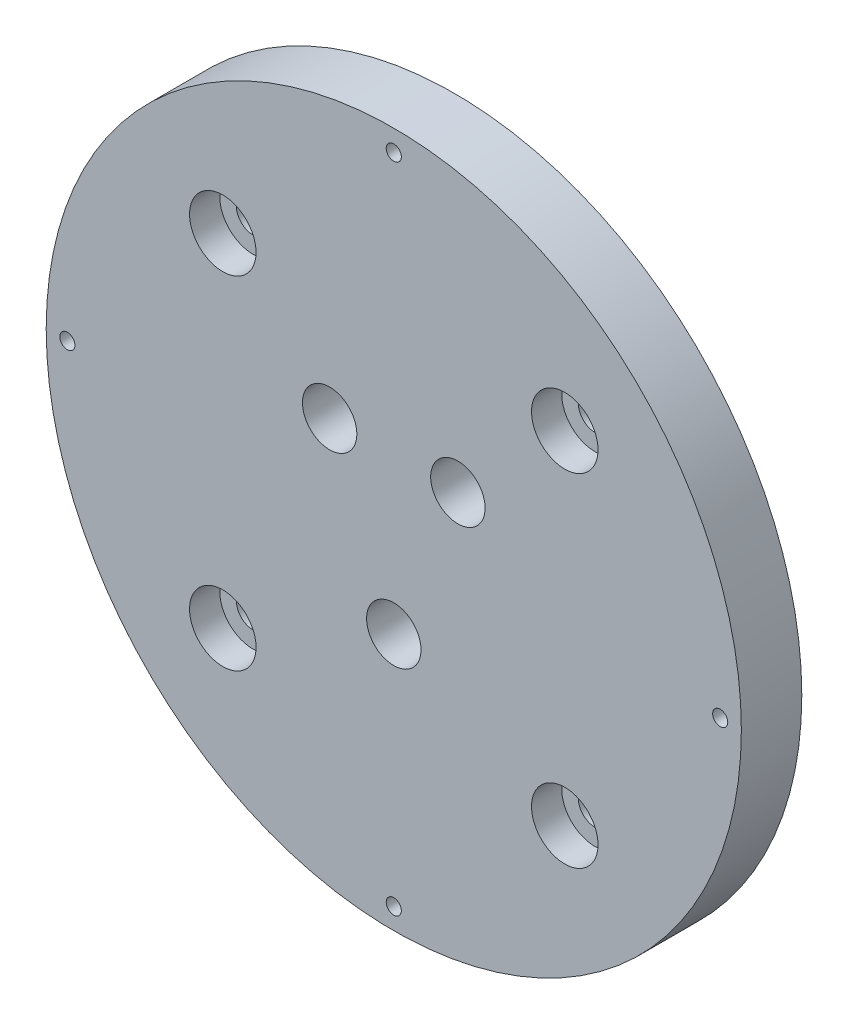
from build123d import *

# Parameters (mm, degrees)
SKETCH1_R           = 57.5
BOSS_EXTRUDE1_DEPTH = 10
SKETCH3_R           = 4.5
CUT_EXTRUDE2_DEPTH  = 10
SKETCH8_R           = 55
SKETCH8_R_2         = 53
CUT_EXTRUDE6_DEPTH  = 1.27
CIRPATTERN2_COUNT   = 4
HOLE1_D             = 5.5
HOLE1_DEPTH         = 10
HOLE1_CBORE_D       = 11
HOLE1_CBORE_DEPTH   = 5
CIRPATTERN3_COUNT   = 4


with BuildPart() as part:
    # Sketch1 → Boss-Extrude1 (new body)
    with BuildSketch(Plane.XY):
        Circle(SKETCH1_R)
    extrude(amount=BOSS_EXTRUDE1_DEPTH)

    # Sketch3 → Cut-Extrude2 (cut)
    with BuildSketch(Plane.XY.offset(10)):
        with Locations((0, -15)):
            Circle(SKETCH3_R)
        with Locations((10.606601718, 10.606601718)):
            Circle(SKETCH3_R)
        with Locations((-10.606601718, 10.606601718)):
            Circle(SKETCH3_R)
    extrude(amount=-CUT_EXTRUDE2_DEPTH, mode=Mode.SUBTRACT)

    # Sketch8 → Cut-Extrude6 (cut)
    with BuildSketch(Plane(origin=(0, 0, 0), x_dir=(-1, 0, 0), z_dir=(0, 0, -1))):
        Circle(SKETCH8_R)
        Circle(SKETCH8_R_2, mode=Mode.SUBTRACT)
    extrude(amount=-CUT_EXTRUDE6_DEPTH, mode=Mode.SUBTRACT)

    # Sketch10 → M3 Tapped Hole1 (revolve, cut)
    with BuildSketch(Plane(origin=(0, 54, 10), x_dir=(0, -1, 0), z_dir=(1, 0, 0))):
        Polygon((0, 0), (0, 7.251075774), (1.25, 6.5), (1.25, 0), align=None)
    m3_tapped_hole1 = revolve(axis=Axis((0, 54, 16.35), (0, 0, -1)), mode=Mode.SUBTRACT)

    # CirPattern2: M3 Tapped Hole1 ×4 about axis
    cirpattern2_axis = Axis((0, 0, 0), (0, 0, 1))
    for i in range(1, CIRPATTERN2_COUNT):
        add(m3_tapped_hole1.rotate(cirpattern2_axis, i * 360 / CIRPATTERN2_COUNT), mode=Mode.SUBTRACT)

    # Hole1
    with Locations(Plane.XY.offset(10)):
        with Locations((28.284271247, 28.284271247)):
            hole1 = CounterBoreHole(HOLE1_D / 2, HOLE1_CBORE_D / 2, HOLE1_CBORE_DEPTH, depth=HOLE1_DEPTH)

    # CirPattern3: Hole1 ×4 about axis
    cirpattern3_axis = Axis((0, 0, 0), (0, 0, 1))
    for i in range(1, CIRPATTERN3_COUNT):
        add(hole1.rotate(cirpattern3_axis, i * 360 / CIRPATTERN3_COUNT), mode=Mode.SUBTRACT)


solid = part.part
